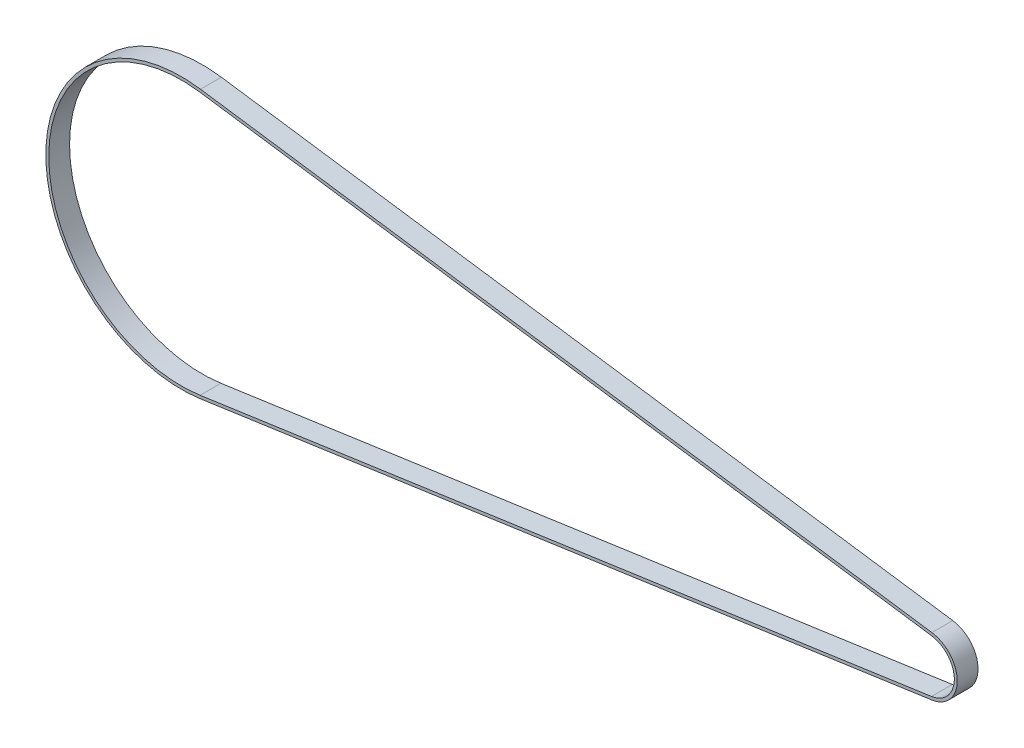
from build123d import *

# Parameters (mm, degrees)
EXTRUDE_THIN1_DEPTH = 14.224


with BuildPart() as part:
    # Sketch2 → Extrude-Thin1 (new body)
    with BuildSketch(Plane.XY):
        with BuildLine():
            Line((-496.863202176, 91.613929858), (2.861676059, 19.956871777))
            ThreePointArc((2.861676059, 19.956871777), (20.161, 0), (2.861676059, -19.956871777))
            Line((2.861676059, -19.956871777), (-496.863202176, -91.613929858))
            ThreePointArc((-496.863202176, -91.613929858), (-602.551, 0), (-496.863202176, 91.613929858))
        make_face()
        with BuildLine():
            Line((-497.147084529, 89.634179669), (2.577793706, 17.977121589))
            ThreePointArc((2.577793706, 17.977121589), (18.161, 0), (2.577793706, -17.977121589))
            Line((2.577793706, -17.977121589), (-497.147084529, -89.634179669))
            ThreePointArc((-497.147084529, -89.634179669), (-600.551, 0), (-497.147084529, 89.634179669))
        make_face(mode=Mode.SUBTRACT)
    extrude(amount=-EXTRUDE_THIN1_DEPTH)


solid = part.part
